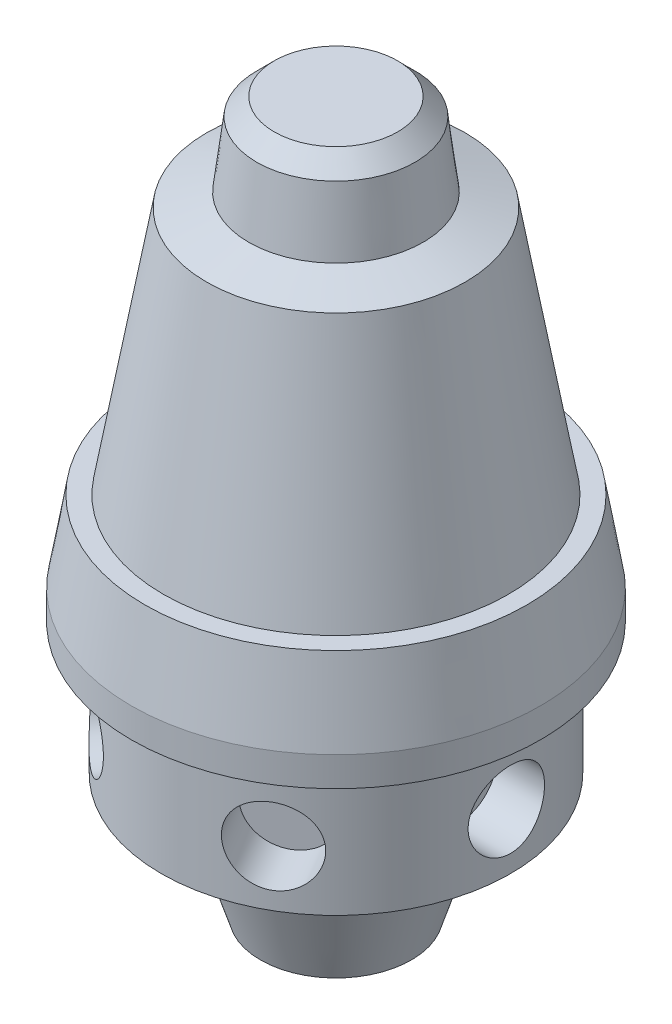
from build123d import *

# Parameters (mm, degrees)
SKETCH_2_R          = 7
CUT_EXTRUDE_1_DEPTH = 15
SKETCH_3_R          = 7
CUT_EXTRUDE_2_DEPTH = 15
SKETCH_4_R          = 7
CUT_EXTRUDE_3_DEPTH = 15
SKETCH_5_R          = 7
CUT_EXTRUDE_4_DEPTH = 15


with BuildPart() as part:
    # Эскиз1 → Повернуть1 (revolve)
    with BuildSketch(Plane.XY):
        Polygon((0, 0), (13.832956578, 0), (21.093288223, 22.779290537), (32, 22.779290537), (32, 46.779290537), (37.5, 46.779290537), (37.5, 52.174655371), (35, 66.934934907), (31.630138236, 66.934934907), (23.700917658, 112.523953152), (15.988556841, 114.982076121), (14.50917162, 126.947847272), (11.301374522, 130.155644371), (0, 130.155644371), align=None)
    revolve(axis=Axis((0, 138.703973398, 0), (0, -1, 0)))

    # Эскиз2 → Вырез-Вытянуть1 (cut)
    with BuildSketch(Plane(origin=(-37.5, 0, 0), x_dir=(0, 1, 0), z_dir=(-1, 0, 0))):
        with Locations((33, 0)):
            Circle(SKETCH_2_R)
    extrude(amount=-CUT_EXTRUDE_1_DEPTH, mode=Mode.SUBTRACT)

    # Эскиз3 → Вырез-Вытянуть2 (cut)
    with BuildSketch(Plane(origin=(18.75, 0, 32.475952642), x_dir=(0, 1, 0), z_dir=(0.5, 0, 0.866025404))):
        with Locations((33, 0)):
            Circle(SKETCH_3_R)
    extrude(amount=-CUT_EXTRUDE_2_DEPTH, mode=Mode.SUBTRACT)

    # Эскиз4 → Вырез-Вытянуть3 (cut)
    with BuildSketch(Plane(origin=(-23.087305325, 0, 29.55040326), x_dir=(0, 1, 0), z_dir=(-0.615661475, 0, 0.788010754))):
        with Locations((33, 0)):
            Circle(SKETCH_4_R)
    extrude(amount=-CUT_EXTRUDE_3_DEPTH, mode=Mode.SUBTRACT)

    # Эскиз5 → Вырез-Вытянуть4 (cut)
    with BuildSketch(Plane.YZ.offset(37.5)):
        with Locations((33, 0)):
            Circle(SKETCH_5_R)
    extrude(amount=-CUT_EXTRUDE_4_DEPTH, mode=Mode.SUBTRACT)


solid = part.part
